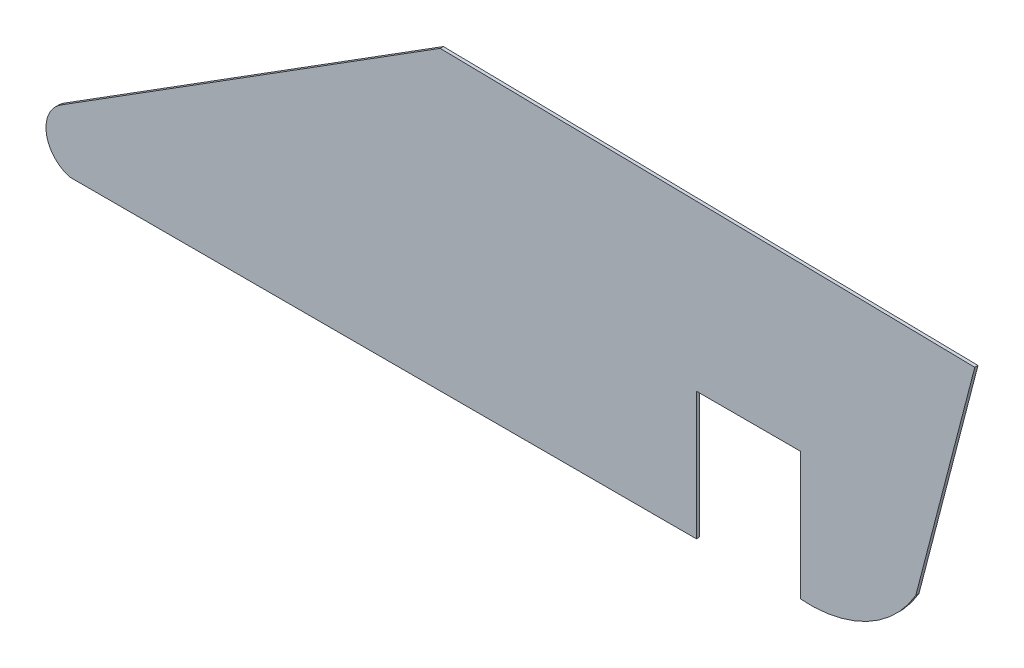
from build123d import *

# Parameters (mm, degrees)
SALIENTE_EXTRUIR1_DEPTH = 0.1


with BuildPart() as part:
    # Model → Saliente-Extruir1 (new body)
    with BuildSketch(Plane.XY):
        with BuildLine():
            Line((33.228973848, 0.17393572), (16.510690428, 0.452082872))
            Line((16.510690428, 0.452082872), (4.649558375, -7.011379622))
            ThreePointArc((4.649558375, -7.011379622), (4.19427636, -8.013126504), (4.9350707, -8.826761725))
            Line((4.9350707, -8.826761725), (9.27203732, -8.826761725))
            Line((9.27203732, -8.826761725), (24.522151852, -8.826761725))
            Line((24.522151852, -8.826761725), (24.522151852, -4.826761725))
            Line((24.522151852, -4.826761725), (27.772151852, -4.826761725))
            Line((27.772151852, -4.826761725), (27.772151852, -8.826761725))
            ThreePointArc((27.772151852, -8.826761725), (29.852156514, -8.399354323), (31.383104023, -6.927859775))
            Line((31.383104023, -6.927859775), (33.228973848, 0.17393572))
        make_face()
    extrude(amount=SALIENTE_EXTRUIR1_DEPTH)


solid = part.part
